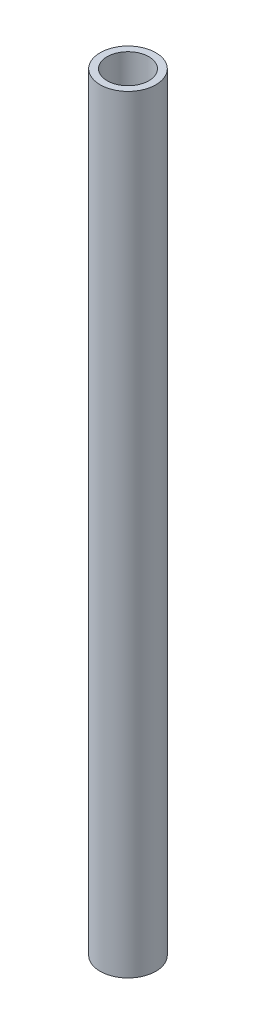
from build123d import *

# Parameters (mm, degrees)
SKETCH1_R           = 12.7
SKETCH1_R_2         = 9.525
BOSS_EXTRUDE2_DEPTH = 350.52


with BuildPart() as part:
    # Sketch1 → Boss-Extrude2 (new body)
    with BuildSketch(Plane(origin=(0, 0, 0), x_dir=(1, 0, 0), z_dir=(0, 1, 0))):
        with Locations((-391.181668083, 212.743279788)):
            Circle(SKETCH1_R)
        with Locations((-391.181668083, 212.743279788)):
            Circle(SKETCH1_R_2, mode=Mode.SUBTRACT)
    extrude(amount=BOSS_EXTRUDE2_DEPTH)


solid = part.part
